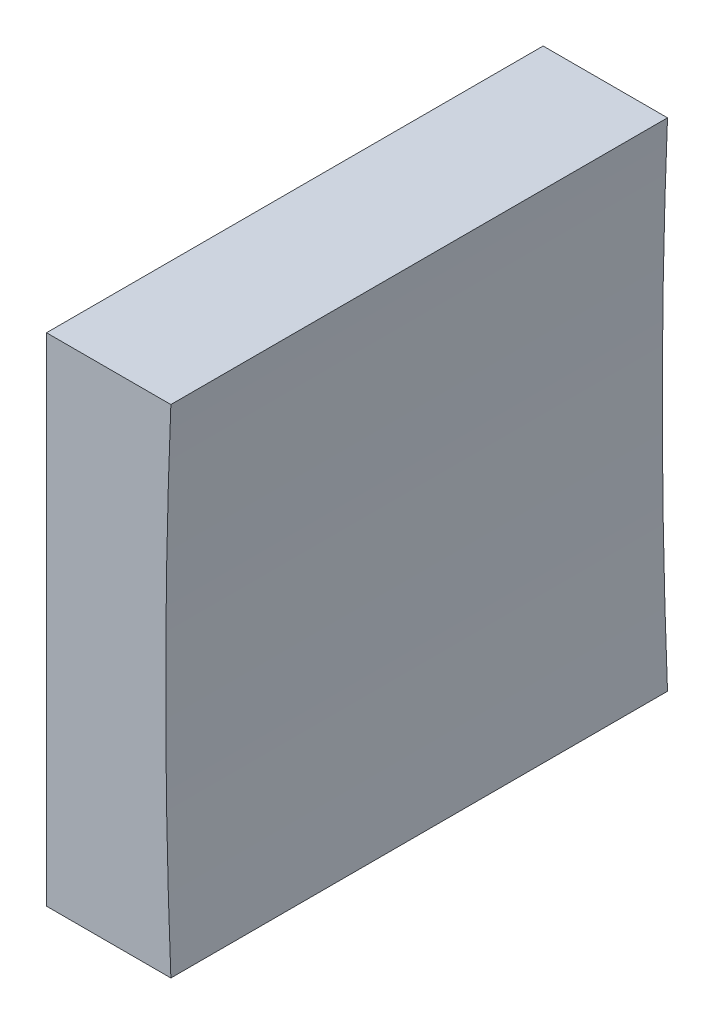
from build123d import *

# Parameters (mm, degrees)
EXTRUDE_1_DEPTH = 25


with BuildPart() as part:
    # 草图1 → 凸台-拉伸1 (new body)
    with BuildSketch(Plane.XY):
        with BuildLine():
            Line((284.707135631, 66.857929268), (284.707135631, 79.357929268))
            Line((284.707135631, 79.357929268), (290.967665424, 79.357929268))
            ThreePointArc((290.967665424, 79.357929268), (290.707135631, 66.857929268), (290.967665424, 54.357929268))
            Line((290.967665424, 54.357929268), (284.707135631, 54.357929268))
            Line((284.707135631, 54.357929268), (284.707135631, 66.857929268))
        make_face()
    extrude(amount=EXTRUDE_1_DEPTH)


solid = part.part
